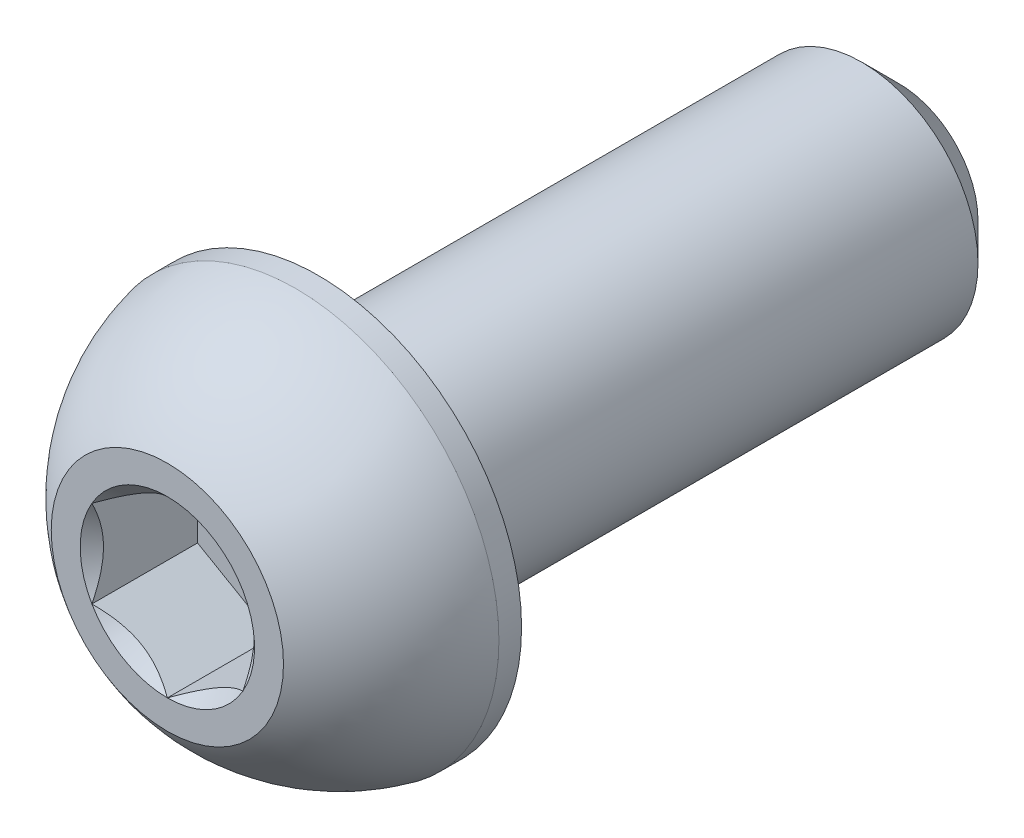
from build123d import *

# Parameters (mm, degrees)
CUT_EXTRUDE1_DEPTH = 0.91


with BuildPart() as part:
    # Sketch2 → Revolve1 (revolve)
    with BuildSketch(Plane(origin=(0, 0, 0), x_dir=(0, 0, -1), z_dir=(1, 0, 0)), mode=Mode.PRIVATE) as revolve1_sk:
        with BuildLine():
            Line((-3.15, 0), (3.15, 0))
            Line((3.15, 0), (3.15, 0.68))
            Line((3.15, 0.68), (2.83, 1))
            Line((2.83, 1), (-1.85, 1))
            Line((-1.85, 1), (-1.85, 1.75))
            Line((-1.85, 1.75), (-2.045, 1.75))
            ThreePointArc((-2.045, 1.75), (-2.670023043, 1.481850617), (-3.15, 1))
            Line((-3.15, 1), (-3.15, 0))
        make_face()
    revolve(revolve1_sk.sketch.rotate(Axis((0, 0, 3.15), (0, 0, -1)), 90), axis=Axis((0, 0, 3.15), (0, 0, -1)))

    # Sketch3 → Cut-Extrude1 (cut)
    with BuildSketch(Plane.XY.offset(3.15)):
        Polygon((0, 0.75055535), (-0.65, 0.375277675), (-0.65, -0.375277675), (0, -0.75055535), (0.65, -0.375277675), (0.65, 0.375277675), align=None)
    extrude(amount=-CUT_EXTRUDE1_DEPTH, mode=Mode.SUBTRACT)

    # Cut-Extrude2 cone 1 section (through the dimple's axis) → Cut-Extrude2 (revolve, cut)
    with BuildSketch(Plane(origin=(0, 0, 3.15), x_dir=(0, -1, 0), z_dir=(1, 0, 0))):
        Polygon((0, 0), (0.75055535, 0), (0, 0.75055535), align=None)
    revolve(axis=Axis((0, 0, 3.15), (0, 0, -1)), mode=Mode.SUBTRACT)


solid = part.part
